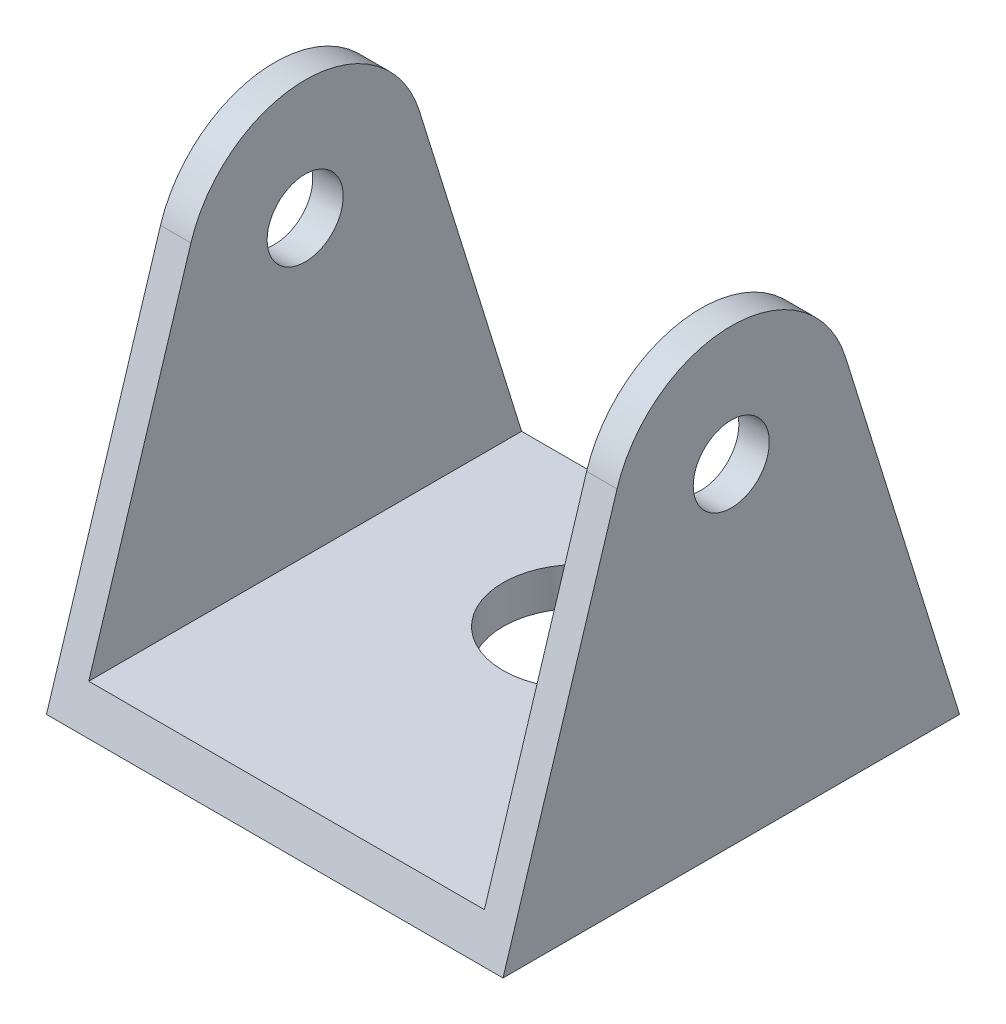
from build123d import *

# Parameters (mm, degrees)
SKETCH1_W           = 30
SKETCH1_H           = 30
BOSS_EXTRUDE1_DEPTH = 2.5
SKETCH2_R           = 5
CUT_EXTRUDE1_DEPTH  = 2.5
SKETCH4_W           = 2
SKETCH4_H           = 30
BOSS_EXTRUDE2_DEPTH = 31.75
SKETCH5_R           = 2.5
CUT_EXTRUDE2_DEPTH  = 30.75
CUT_EXTRUDE3_DEPTH  = 30.75


with BuildPart() as part:
    # Sketch1 → Boss-Extrude1 (new body)
    with BuildSketch(Plane(origin=(0, 0, 0), x_dir=(1, 0, 0), z_dir=(0, 1, 0))):
        Rectangle(SKETCH1_W, SKETCH1_H)
    extrude(amount=BOSS_EXTRUDE1_DEPTH)

    # Sketch2 → Cut-Extrude1 (cut)
    with BuildSketch(Plane(origin=(0, 2.5, 0), x_dir=(1, 0, 0), z_dir=(0, 1, 0))):
        with Locations((0, 5)):
            Circle(SKETCH2_R)
    extrude(amount=-CUT_EXTRUDE1_DEPTH, mode=Mode.SUBTRACT)

    # Sketch4 → Boss-Extrude2 (add)
    with BuildSketch(Plane(origin=(0, 2.5, 0), x_dir=(1, 0, 0), z_dir=(0, 1, 0))):
        with Locations((-14, 0)):
            Rectangle(SKETCH4_W, SKETCH4_H)
        with Locations((14, 0)):
            Rectangle(SKETCH4_W, SKETCH4_H)
    extrude(amount=BOSS_EXTRUDE2_DEPTH)

    # Sketch5 → Cut-Extrude2 (cut)
    with BuildSketch(Plane.ZY.offset(15)):
        with Locations((0, 21.75)):
            Circle(SKETCH5_R)
    extrude(amount=-CUT_EXTRUDE2_DEPTH, mode=Mode.SUBTRACT)

    # Sketch6 → Cut-Extrude3 (cut)
    with BuildSketch(Plane.ZY.offset(15)):
        with BuildLine():
            Line((-15, 0), (-7.505901536, 24.085434897))
            ThreePointArc((-7.505901536, 24.085434897), (0, 29.610840542), (7.505901536, 24.085434897))
            Line((7.505901536, 24.085434897), (15, 0))
            Line((15, 0), (15, 34.25))
            Line((15, 34.25), (-15, 34.25))
            Line((-15, 34.25), (-15, 0))
        make_face()
    extrude(amount=-CUT_EXTRUDE3_DEPTH, mode=Mode.SUBTRACT)


solid = part.part
